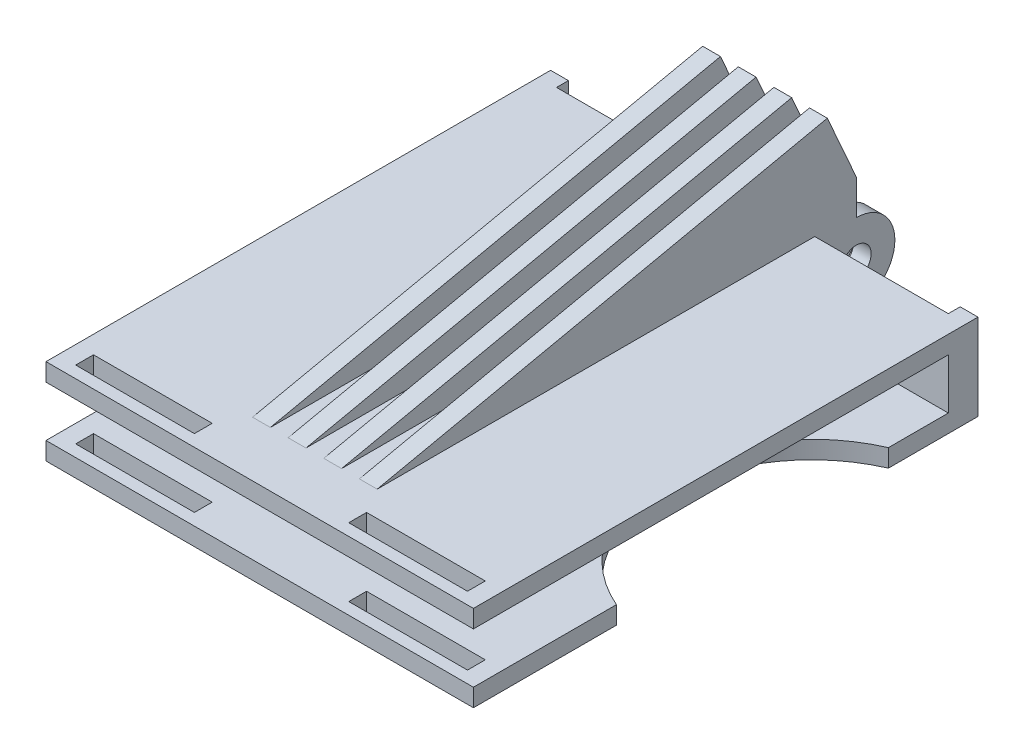
from build123d import *

# Parameters (mm, degrees)
SKETCH_1_W          = 72
SKETCH_1_H          = 14.5
EXTRUDE_1_DEPTH     = 3
SKETCH_2_W          = 72
SKETCH_2_H          = 3
EXTRUDE_2_DEPTH     = 80
SKETCH_3_W          = 3
SKETCH_3_H          = 13
EXTRUDE_3_DEPTH     = 13.5
SKETCH_4_R          = 2.5
CUT_EXTRUDE_1_DEPTH = 21
SKETCH_5_W          = 20
SKETCH_5_H          = 3
CUT_EXTRUDE_2_DEPTH = 21
SKETCH_6_W          = 3
SKETCH_6_H          = 14.5
EXTRUDE_5_DEPTH     = 2
SKETCH_8_W          = 3
SKETCH_8_H          = 80.708275322
EXTRUDE_6_DEPTH     = 18
CUT_EXTRUDE_3_DEPTH = 21
SKETCH_12_R         = 25
CUT_EXTRUDE_5_DEPTH = 8
CUT_EXTRUDE_6_DEPTH = 31


with BuildPart() as part:
    # 草图1 → 凸台-拉伸1 (new body)
    with BuildSketch(Plane.XY):
        with Locations((36, 7.25)):
            Rectangle(SKETCH_1_W, SKETCH_1_H)
    extrude(amount=EXTRUDE_1_DEPTH)

    # 草图2 → 凸台-拉伸2 (add)
    with BuildSketch(Plane.XY.offset(3)):
        with Locations((36, 1.5)):
            Rectangle(SKETCH_2_W, SKETCH_2_H)
        with Locations((36, 13)):
            Rectangle(SKETCH_2_W, SKETCH_2_H)
    extrude(amount=EXTRUDE_2_DEPTH)

    # 草图3 → 凸台-拉伸3 (add)
    with BuildSketch(Plane(origin=(0, 0, 0), x_dir=(-1, 0, 0), z_dir=(0, 0, -1))):
        with Locations((-39, 7.25)):
            Rectangle(SKETCH_3_W, SKETCH_3_H)
        Polygon((-43.5, 0.75), (-43.5, 7.25), (-43.5, 13.75), (-46.5, 13.75), (-46.5, 0.75), align=None)
        with Locations((-33, 7.25)):
            Rectangle(SKETCH_3_W, SKETCH_3_H)
        Polygon((-28.5, 7.25), (-28.5, 13.75), (-25.5, 13.75), (-25.5, 0.75), (-28.5, 0.75), align=None)
    extrude(amount=EXTRUDE_3_DEPTH)

    # 草图4 → 切除-拉伸1 (cut)
    with BuildSketch(Plane.ZY.offset(-25.5)):
        with Locations((-7, 7.25)):
            Circle(SKETCH_4_R)
        with BuildLine():
            Line((-7, 0.75), (-7, -0.932690229))
            Line((-7, -0.932690229), (-15.150689601, -0.932690229))
            Line((-15.150689601, -0.932690229), (-15.150689601, 14.849085894))
            Line((-15.150689601, 14.849085894), (-7, 13.75))
            ThreePointArc((-7, 13.75), (-13.5, 7.25), (-7, 0.75))
        make_face()
    extrude(amount=-CUT_EXTRUDE_1_DEPTH, mode=Mode.SUBTRACT)

    # 草图5 → 切除-拉伸2 (cut)
    with BuildSketch(Plane(origin=(0, 14.5, 0), x_dir=(1, 0, 0), z_dir=(0, 1, 0))):
        with Locations((13, -79.5)):
            Rectangle(SKETCH_5_W, SKETCH_5_H)
        with Locations((59, -79.5)):
            Rectangle(SKETCH_5_W, SKETCH_5_H)
    extrude(amount=-CUT_EXTRUDE_2_DEPTH, mode=Mode.SUBTRACT)

    # 草图6 → 凸台-拉伸5 (add)
    with BuildSketch(Plane(origin=(0, 0, 0), x_dir=(-1, 0, 0), z_dir=(0, 0, -1))):
        with Locations((-70.5, 7.25)):
            Rectangle(SKETCH_6_W, SKETCH_6_H)
        with Locations((-1.5, 7.25)):
            Rectangle(SKETCH_6_W, SKETCH_6_H)
    extrude(amount=EXTRUDE_5_DEPTH)

    # 草图8 → 凸台-拉伸6 (add)
    with BuildSketch(Plane(origin=(0, 13.75, 0), x_dir=(1, 0, 0), z_dir=(0, 1, 0))):
        with Locations((27, -33.354137661)):
            Rectangle(SKETCH_8_W, SKETCH_8_H)
        with Locations((33, -33.354137661)):
            Rectangle(SKETCH_8_W, SKETCH_8_H)
        with Locations((39, -33.354137661)):
            Rectangle(SKETCH_8_W, SKETCH_8_H)
        with Locations((45, -33.354137661)):
            Rectangle(SKETCH_8_W, SKETCH_8_H)
    extrude(amount=EXTRUDE_6_DEPTH)

    # 草图9 → 切除-拉伸3 (cut)
    with BuildSketch(Plane.ZY.offset(-25.5)):
        Polygon((-7, 31.75), (73.708275322, 14.5), (73.708275322, 31.75), align=None)
    extrude(amount=-CUT_EXTRUDE_3_DEPTH, mode=Mode.SUBTRACT)

    # 草图12 → 切除-拉伸5 (cut)
    with BuildSketch(Plane.XZ):
        with Locations((82, 36)):
            Circle(SKETCH_12_R)
    extrude(amount=-CUT_EXTRUDE_5_DEPTH, mode=Mode.SUBTRACT)

    # 草图13 → 切除-拉伸6 (cut)
    with BuildSketch(Plane.ZY.offset(-25.5)):
        Polygon((-7, 19.685447093), (-2.115986675, 30.7061265), (-3.141307931, 37.349064324), (-11.498288127, 31.75), align=None)
    extrude(amount=-CUT_EXTRUDE_6_DEPTH, mode=Mode.SUBTRACT)


solid = part.part
